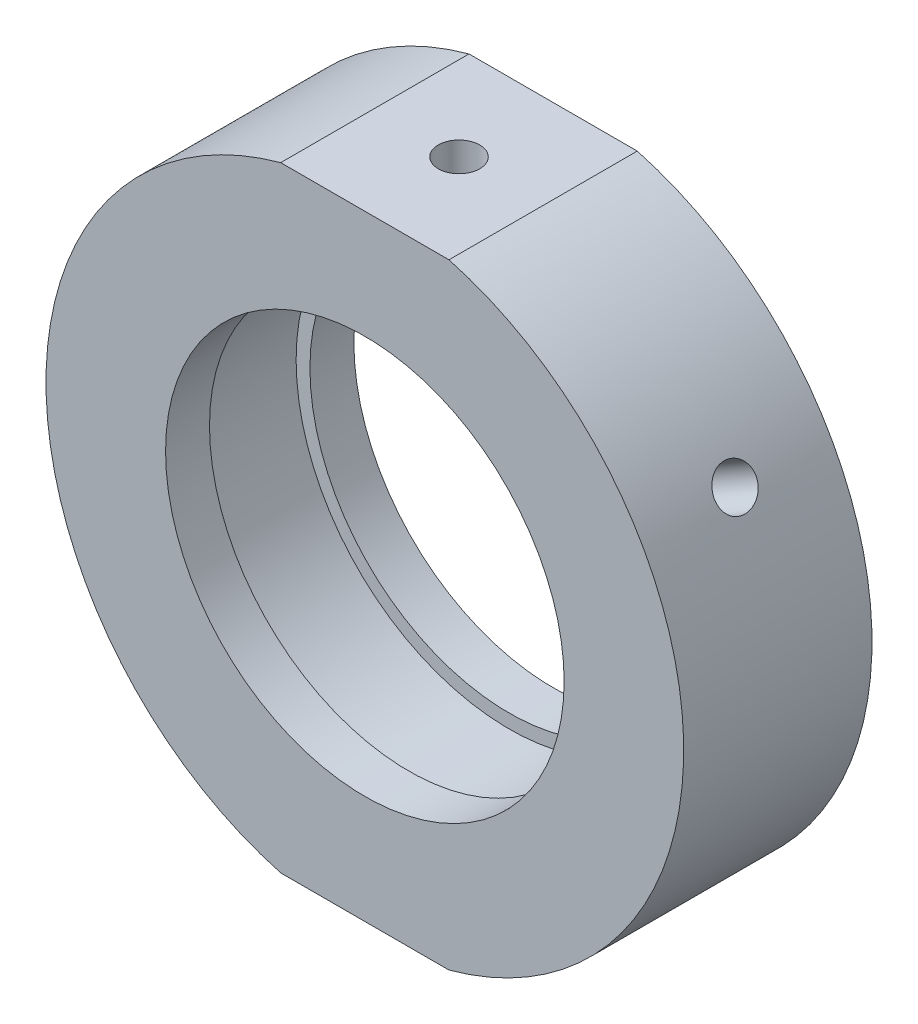
from build123d import *

# Parameters (mm, degrees)
SKETCH_2_W                       = 64.02174429
SKETCH_2_H                       = 9.248919907
CUT_EXTRUDE_1_DEPTH              = 49
HOLE_WIZARD_M4_2_D               = 3.3
HOLE_WIZARD_M4_2_DEPTH           = 5.5
HOLE_WIZARD_M4_2_TIP             = 0.991420021
HOLE_WIZARD_M6_2_D               = 5
HOLE_WIZARD_M6_2_DEPTH           = 5.5
HOLE_WIZARD_M6_2_TIP             = 1.502151548
HOLE_WIZARD_M4_3_D               = 3.3
HOLE_WIZARD_M4_3_DEPTH           = 13.4
HOLE_WIZARD_M4_3_TIP             = 0.991420021
HOLE_WIZARD_M4_3_ON_FACE_2_D     = 3.3
HOLE_WIZARD_M4_3_ON_FACE_2_DEPTH = 13.4
HOLE_WIZARD_M4_3_ON_FACE_2_TIP   = 0.991420021


with BuildPart() as part:
    # 草图1 → 旋转1 (revolve)
    with BuildSketch(Plane(origin=(0, 0, 0), x_dir=(1, 0, 0), z_dir=(0, 1, 0)), mode=Mode.PRIVATE) as revolve_1_sk:
        Polygon((25.4, 7.5), (25.4, -7.5), (15.875, -7.5), (15.875, -4), (16.975, -4), (16.975, 4), (15.875, 4), (15.875, 7.5), align=None)
    revolve(revolve_1_sk.sketch.rotate(Axis((0, 0, -31.9390681), (0, 0, 1)), 180), axis=Axis((0, 0, -31.9390681), (0, 0, 1)))  # turned: the seam where the file's is

    # 草图2 → 切除-拉伸1 (cut)
    with BuildSketch(Plane.XY.offset(7.5)):
        with Locations((-1.141100508, 29.124459954)):
            Rectangle(SKETCH_2_W, SKETCH_2_H)
        with Locations((-1.141100508, -29.124459954)):
            Rectangle(SKETCH_2_W, SKETCH_2_H)
    extrude(amount=-CUT_EXTRUDE_1_DEPTH, mode=Mode.SUBTRACT)

    # M4 螺纹孔2
    with Locations(Plane(origin=(0, 24.5, 0), x_dir=(1, 0, 0), z_dir=(0, 1, 0))):
        with Locations((0, 0)):
            Hole(HOLE_WIZARD_M4_2_D / 2, depth=HOLE_WIZARD_M4_2_DEPTH)
            with Locations((0, 0, -(HOLE_WIZARD_M4_2_DEPTH + HOLE_WIZARD_M4_2_TIP / 2))):  # 118° drill point
                Cone(0, HOLE_WIZARD_M4_2_D / 2, HOLE_WIZARD_M4_2_TIP, mode=Mode.SUBTRACT)

    # M6 螺纹孔2
    with Locations(Plane(origin=(0, -24.5, 0), x_dir=(-1, 0, 0), z_dir=(0, -1, 0))):
        with Locations((0, 0)):
            Hole(HOLE_WIZARD_M6_2_D / 2, depth=HOLE_WIZARD_M6_2_DEPTH)
            with Locations((0, 0, -(HOLE_WIZARD_M6_2_DEPTH + HOLE_WIZARD_M6_2_TIP / 2))):  # 118° drill point
                Cone(0, HOLE_WIZARD_M6_2_D / 2, HOLE_WIZARD_M6_2_TIP, mode=Mode.SUBTRACT)

    # M4 螺纹孔3
    with Locations(Plane(origin=(21.997045256, 12.7, 0), x_dir=(-0.5, 0.866025404, 0), z_dir=(0.866025404, 0.5, 0))):
        with Locations((0, 0)):
            Hole(HOLE_WIZARD_M4_3_D / 2, depth=HOLE_WIZARD_M4_3_DEPTH)
            with Locations((0, 0, -(HOLE_WIZARD_M4_3_DEPTH + HOLE_WIZARD_M4_3_TIP / 2))):  # 118° drill point
                Cone(0, HOLE_WIZARD_M4_3_D / 2, HOLE_WIZARD_M4_3_TIP, mode=Mode.SUBTRACT)

    # M4 螺纹孔3 on face 2
    with Locations(Plane(origin=(-21.997045256, 12.7, 0), x_dir=(-0.500000175, -0.866025303, 0), z_dir=(-0.866025303, 0.500000175, 0))):
        with Locations((0, 0)):
            Hole(HOLE_WIZARD_M4_3_ON_FACE_2_D / 2, depth=HOLE_WIZARD_M4_3_ON_FACE_2_DEPTH)
            with Locations((0, 0, -(HOLE_WIZARD_M4_3_ON_FACE_2_DEPTH + HOLE_WIZARD_M4_3_ON_FACE_2_TIP / 2))):  # 118° drill point
                Cone(0, HOLE_WIZARD_M4_3_ON_FACE_2_D / 2, HOLE_WIZARD_M4_3_ON_FACE_2_TIP, mode=Mode.SUBTRACT)


solid = part.part
